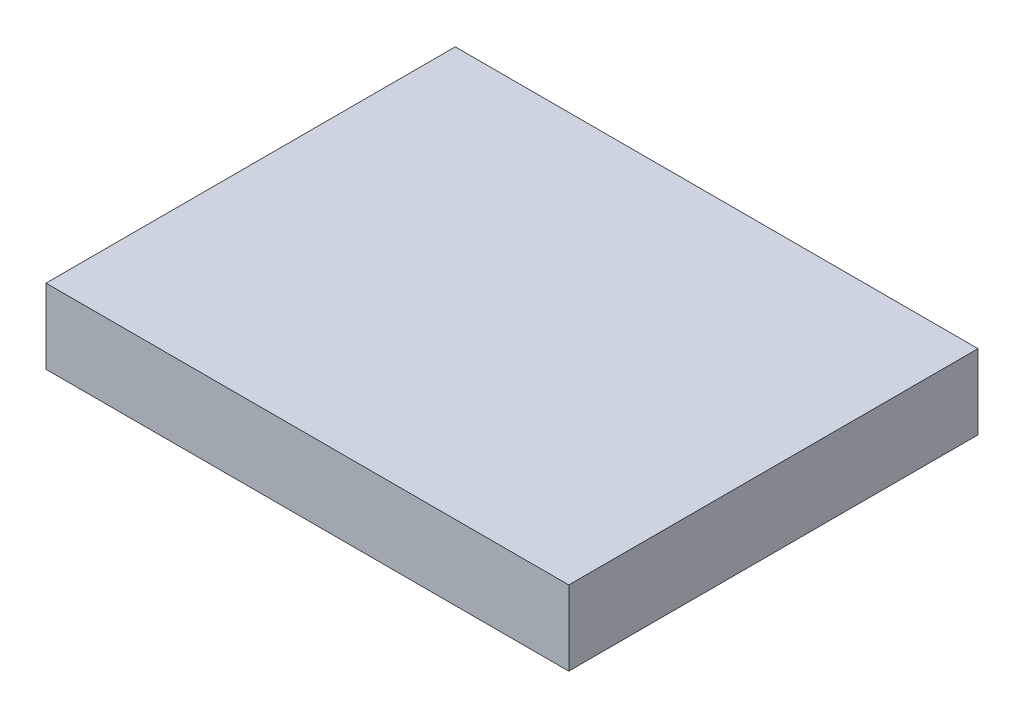
from build123d import *

# Parameters (mm, degrees)
SKETCH1_W           = 44.45
SKETCH1_H           = 34.798
BOSS_EXTRUDE1_DEPTH = 3.175


with BuildPart() as part:
    # Sketch1 → Boss-Extrude1 (new body, symmetric)
    with BuildSketch(Plane(origin=(0, 0, 0), x_dir=(1, 0, 0), z_dir=(0, 1, 0))):
        Rectangle(SKETCH1_W, SKETCH1_H)
    extrude(amount=BOSS_EXTRUDE1_DEPTH, both=True)


solid = part.part
